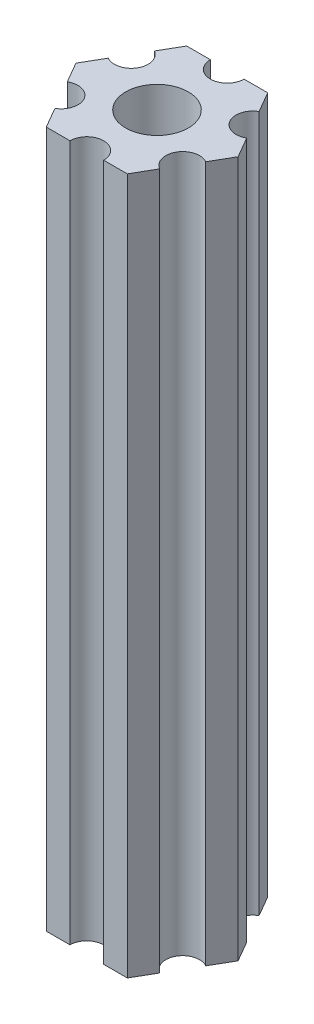
from build123d import *

# Parameters (mm, degrees)
ESBO_O1_R                = 2.79
RESSALTO_EXTRUS_O1_DEPTH = 62


with BuildPart() as part:
    # Esboço1 → Ressalto-extrusão1 (new body)
    with BuildSketch(Plane(origin=(0, 85, 0), x_dir=(1, 0, 0), z_dir=(0, 1, 0))):
        with BuildLine():
            Line((6.162658774, -1.825961894), (7.216878365, 0))
            Line((7.216878365, 0), (6.162658774, 1.825961894))
            ThreePointArc((6.162658774, 1.825961894), (4.113620668, 2.375), (4.662658774, 4.424038106))
            Line((4.662658774, 4.424038106), (3.608439182, 6.25))
            Line((3.608439182, 6.25), (1.5, 6.25))
            ThreePointArc((1.5, 6.25), (0, 4.75), (-1.5, 6.25))
            Line((-1.5, 6.25), (-3.608439182, 6.25))
            Line((-3.608439182, 6.25), (-4.662658774, 4.424038106))
            ThreePointArc((-4.662658774, 4.424038106), (-4.113620668, 2.375), (-6.162658774, 1.825961894))
            Line((-6.162658774, 1.825961894), (-7.216878365, 0))
            Line((-7.216878365, 0), (-6.162658774, -1.825961894))
            ThreePointArc((-6.162658774, -1.825961894), (-4.113620668, -2.375), (-4.662658774, -4.424038106))
            Line((-4.662658774, -4.424038106), (-3.608439182, -6.25))
            Line((-3.608439182, -6.25), (-1.5, -6.25))
            ThreePointArc((-1.5, -6.25), (0, -4.75), (1.5, -6.25))
            Line((1.5, -6.25), (3.608439182, -6.25))
            Line((3.608439182, -6.25), (4.662658774, -4.424038106))
            ThreePointArc((4.662658774, -4.424038106), (4.113620668, -2.375), (6.162658774, -1.825961894))
        make_face()
        Circle(ESBO_O1_R, mode=Mode.SUBTRACT)
    extrude(amount=-RESSALTO_EXTRUS_O1_DEPTH)


solid = part.part
